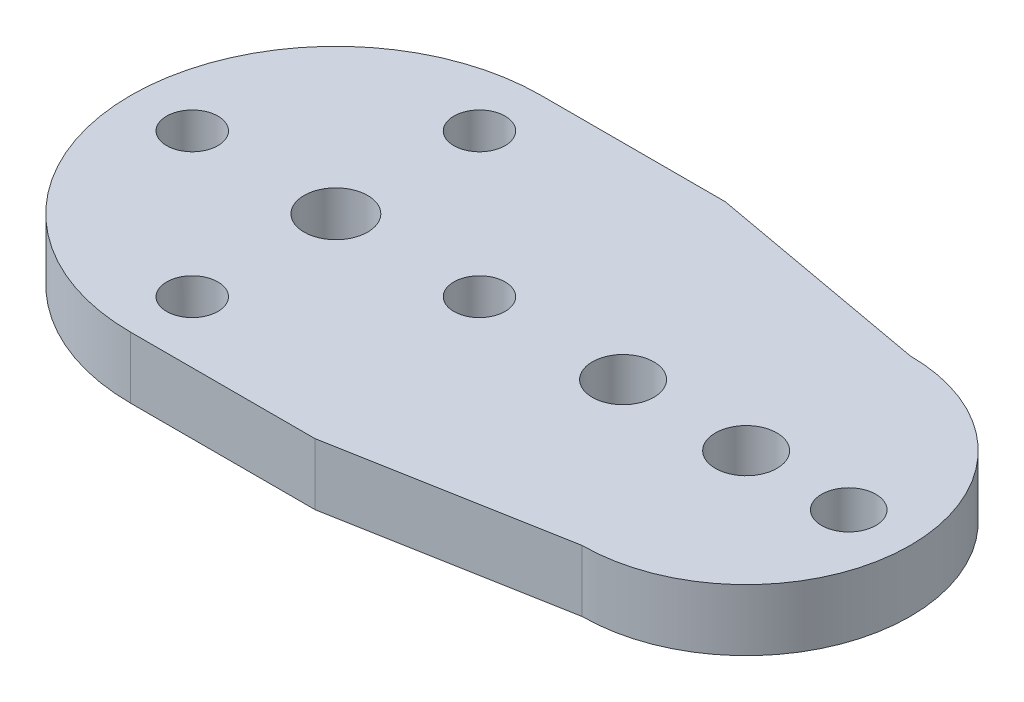
from build123d import *

# Parameters (mm, degrees)
SKETCH2_R           = 1.55
SKETCH2_R_2         = 1.5
BOSS_EXTRUDE2_DEPTH = 3
SKETCH3_R           = 1.25
SKETCH3_R_2         = 1.5
SKETCH3_R_3         = 1.321701339
CUT_EXTRUDE1_DEPTH  = 10


with BuildPart() as part:
    # Sketch2 → Boss-Extrude2 (new body)
    with BuildSketch(Plane(origin=(0, 0, 0), x_dir=(1, 0, 0), z_dir=(0, 1, 0))):
        with BuildLine():
            Line((-80, 0), (-71.018028778, 0))
            Line((-71.018028778, 0), (-60, 2))
            ThreePointArc((-60, 2), (-52, 10), (-60, 18))
            Line((-60, 18), (-71.018028778, 20))
            Line((-71.018028778, 20), (-80, 20))
            ThreePointArc((-80, 20), (-90, 10), (-80, 0))
        make_face()
        with Locations((-80, 10)):
            Circle(SKETCH2_R, mode=Mode.SUBTRACT)
        with Locations((-60, 10)):
            Circle(SKETCH2_R_2, mode=Mode.SUBTRACT)
    extrude(amount=BOSS_EXTRUDE2_DEPTH)

    # Sketch3 → Cut-Extrude1 (cut)
    with BuildSketch(Plane(origin=(0, 0, 0), x_dir=(1, 0, 0), z_dir=(0, 1, 0))):
        with Locations((-80, 17)):
            Circle(SKETCH3_R)
        with Locations((-80, 3)):
            Circle(SKETCH3_R)
        with Locations((-87, 10)):
            Circle(SKETCH3_R)
        with Locations((-73, 10)):
            Circle(SKETCH3_R)
        with Locations((-66, 10)):
            Circle(SKETCH3_R_2)
        with Locations((-55, 10)):
            Circle(SKETCH3_R_3)
    extrude(amount=CUT_EXTRUDE1_DEPTH, mode=Mode.SUBTRACT)


solid = part.part
